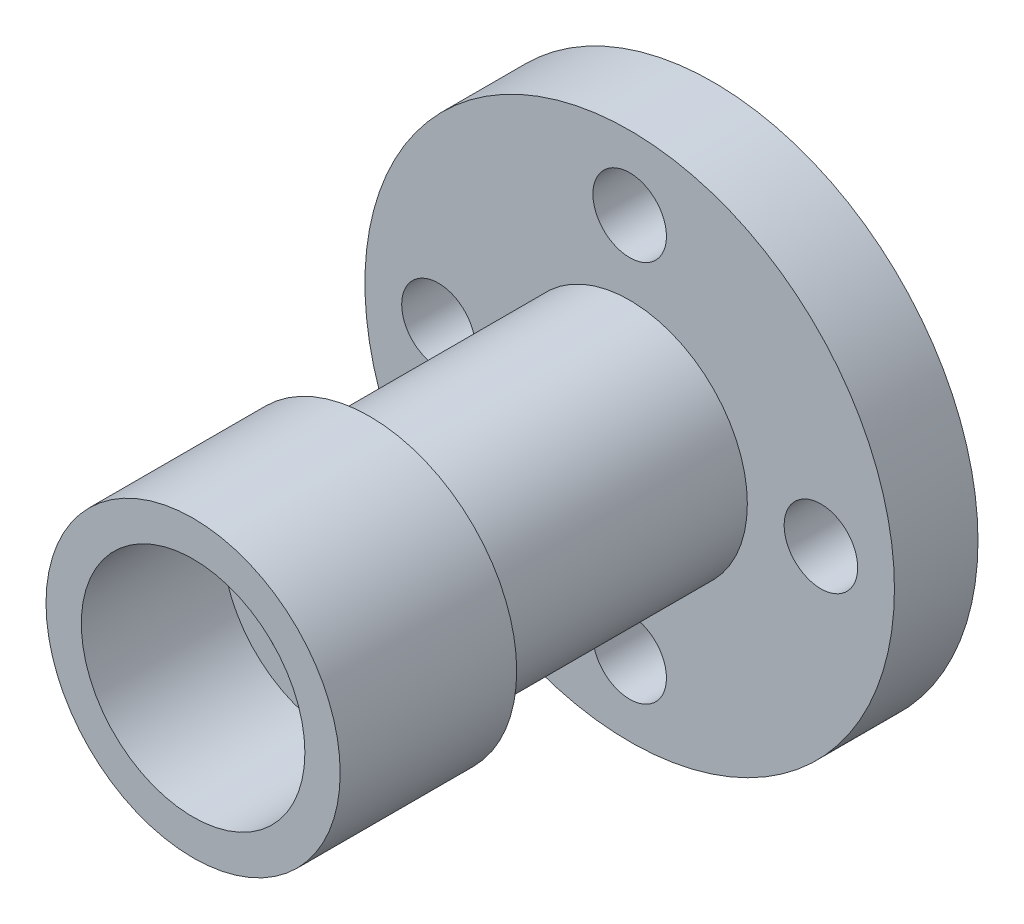
from build123d import *

# Parameters (mm, degrees)
CROQUIS1_R              = 45
SALIENTE_EXTRUIR1_DEPTH = 14.2
CROQUIS2_R              = 20
SALIENTE_EXTRUIR2_DEPTH = 44.2
CROQUIS3_R              = 25
SALIENTE_EXTRUIR3_DEPTH = 30
CROQUIS4_R              = 19
CORTAR_EXTRUIR1_DEPTH   = 24
CROQUIS5_R              = 15
CORTAR_EXTRUIR2_DEPTH   = 84
CHAFL_N1_SIZE           = 3.5
CHAFL_N1_SIZE2          = 3
CROQUIS6_R              = 6.25
CORTAR_EXTRUIR3_DEPTH   = 84


with BuildPart() as part:
    # Croquis1 → Saliente-Extruir1 (new body)
    with BuildSketch(Plane.XY):
        Circle(CROQUIS1_R)
    extrude(amount=SALIENTE_EXTRUIR1_DEPTH)

    # Croquis2 → Saliente-Extruir2 (add)
    with BuildSketch(Plane.XY.offset(14.2)):
        Circle(CROQUIS2_R)
    extrude(amount=SALIENTE_EXTRUIR2_DEPTH)

    # Croquis3 → Saliente-Extruir3 (add)
    with BuildSketch(Plane.XY.offset(58.4)):
        Circle(CROQUIS3_R)
    extrude(amount=SALIENTE_EXTRUIR3_DEPTH)

    # Croquis4 → Cortar-Extruir1 (cut)
    with BuildSketch(Plane.XY.offset(88.4)):
        Circle(CROQUIS4_R)
    extrude(amount=-CORTAR_EXTRUIR1_DEPTH, mode=Mode.SUBTRACT)

    # Croquis5 → Cortar-Extruir2 (cut)
    with BuildSketch(Plane.XY.offset(64.4)):
        Circle(CROQUIS5_R)
    extrude(amount=-CORTAR_EXTRUIR2_DEPTH, mode=Mode.SUBTRACT)

    # Chaflán1
    chafl_n1_edges = [part.edges().sort_by_distance(p)[0] for p in [
        (-15, 0, 0),
    ]]
    chafl_n1_side = [part.faces().sort_by_distance(p)[0] for p in [
        (-15, 0, 32.2),
    ]]
    chamfer(chafl_n1_edges, length=CHAFL_N1_SIZE, length2=CHAFL_N1_SIZE2, reference=chafl_n1_side[0])

    # Croquis6 → Cortar-Extruir3 (cut)
    with BuildSketch(Plane(origin=(0, 0, 0), x_dir=(-1, 0, 0), z_dir=(0, 0, -1))):
        with Locations((0, 32.5)):
            Circle(CROQUIS6_R)
        with Locations((32.5, 0)):
            Circle(CROQUIS6_R)
        with Locations((0, -32.5)):
            Circle(CROQUIS6_R)
        with Locations((-32.5, 0)):
            Circle(CROQUIS6_R)
    extrude(amount=-CORTAR_EXTRUIR3_DEPTH, mode=Mode.SUBTRACT)


solid = part.part
